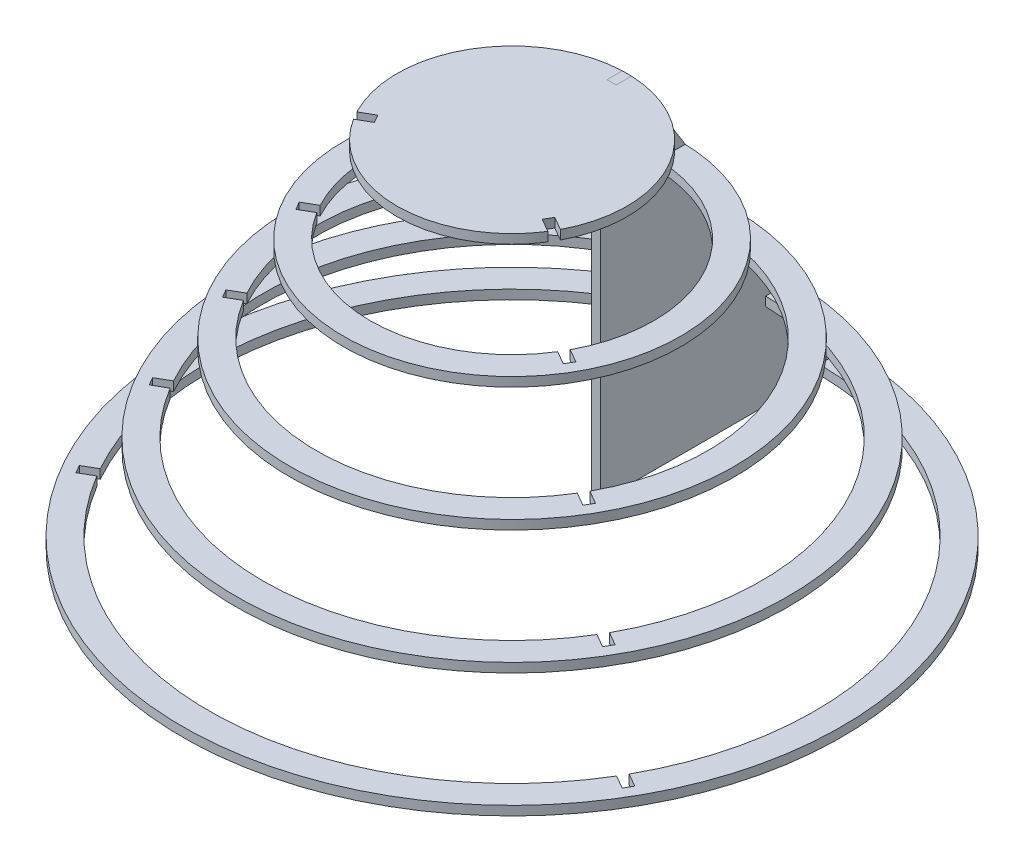
from build123d import *

# Parameters (mm, degrees)
BOSS_EXTRUDE1_DEPTH = 12
SKETCH2_R           = 220
BOSS_EXTRUDE2_DEPTH = 12
SKETCH3_R           = 290
BOSS_EXTRUDE3_DEPTH = 12
SKETCH4_R           = 360
BOSS_EXTRUDE4_DEPTH = 12
SKETCH5_R           = 430
BOSS_EXTRUDE5_DEPTH = 12
BOSS_EXTRUDE6_DEPTH = 12


with BuildPart() as part:
    # Sketch1 → Boss-Extrude1 (new body)
    with BuildSketch(Plane(origin=(0, 0, 0), x_dir=(1, 0, 0), z_dir=(0, 1, 0))):
        with BuildLine():
            Line((109.479337841, -70.136128403), (126.799845917, -80.136128403))
            ThreePointArc((126.799845917, -80.136128403), (0, -150), (-126.799845917, -80.136128403))
            Line((-126.799845917, -80.136128403), (-109.479337841, -70.136128403))
            Line((-109.479337841, -70.136128403), (-115.479337841, -59.743823558))
            Line((-115.479337841, -59.743823558), (-132.799845917, -69.743823558))
            ThreePointArc((-132.799845917, -69.743823558), (-129.903810568, 75), (-6, 149.879951962))
            Line((-6, 149.879951962), (-6, 129.879951962))
            Line((-6, 129.879951962), (6, 129.879951962))
            Line((6, 129.879951962), (6, 149.879951962))
            ThreePointArc((6, 149.879951962), (129.903810568, 75), (132.799845917, -69.743823558))
            Line((132.799845917, -69.743823558), (115.479337841, -59.743823558))
            Line((115.479337841, -59.743823558), (109.479337841, -70.136128403))
        make_face()
    extrude(amount=BOSS_EXTRUDE1_DEPTH)


with BuildPart() as body_2:
    # Sketch2 → Boss-Extrude2 (new body)
    with BuildSketch(Plane(origin=(0, -100, 0), x_dir=(-1, 0, 0), z_dir=(0, -1, 0))):
        Circle(SKETCH2_R)
        with BuildLine():
            Line((180.436842735, -97.247056494), (163.130415599, -87.255186129))
            ThreePointArc((163.130415599, -87.255186129), (160.2146997, 92.5), (6, 184.902677103))
            Line((6, 184.902677103), (6, 204.886417834))
            Line((6, 204.886417834), (-6, 204.886417834))
            Line((-6, 204.886417834), (-6, 184.902677103))
            ThreePointArc((-6, 184.902677103), (-160.2146997, 92.5), (-163.130415599, -87.255186129))
            Line((-163.130415599, -87.255186129), (-180.436842735, -97.247056494))
            Line((-180.436842735, -97.247056494), (-174.436842735, -107.63936134))
            Line((-174.436842735, -107.63936134), (-157.130415599, -97.647490974))
            ThreePointArc((-157.130415599, -97.647490974), (0, -185), (157.130415599, -97.647490974))
            Line((157.130415599, -97.647490974), (174.436842735, -107.63936134))
            Line((174.436842735, -107.63936134), (180.436842735, -97.247056494))
        make_face(mode=Mode.SUBTRACT)
    extrude(amount=BOSS_EXTRUDE2_DEPTH)


with BuildPart() as body_3:
    # Sketch3 → Boss-Extrude3 (new body)
    with BuildSketch(Plane(origin=(0, -212, 0), x_dir=(-1, 0, 0), z_dir=(0, -1, 0))):
        Circle(SKETCH3_R)
        with BuildLine():
            Line((241.095846372, -132.268548573), (223.775338297, -122.268548573))
            ThreePointArc((223.775338297, -122.268548573), (220.836477965, 127.5), (6, 254.929401992))
            Line((6, 254.929401992), (6, 274.929401992))
            Line((6, 274.929401992), (-6, 274.929401992))
            Line((-6, 274.929401992), (-6, 254.929401992))
            ThreePointArc((-6, 254.929401992), (-220.836477965, 127.5), (-223.775338297, -122.268548573))
            Line((-223.775338297, -122.268548573), (-241.095846372, -132.268548573))
            Line((-241.095846372, -132.268548573), (-235.095846372, -142.660853419))
            Line((-235.095846372, -142.660853419), (-217.775338297, -132.660853419))
            ThreePointArc((-217.775338297, -132.660853419), (0, -255), (217.775338297, -132.660853419))
            Line((217.775338297, -132.660853419), (235.095846372, -142.660853419))
            Line((235.095846372, -142.660853419), (241.095846372, -132.268548573))
        make_face(mode=Mode.SUBTRACT)
    extrude(amount=BOSS_EXTRUDE3_DEPTH)


with BuildPart() as body_4:
    # Sketch4 → Boss-Extrude4 (new body)
    with BuildSketch(Plane(origin=(0, -324, 0), x_dir=(-1, 0, 0), z_dir=(0, -1, 0))):
        Circle(SKETCH4_R)
        with BuildLine():
            Line((301.730795734, -167.27615291), (284.410287658, -157.27615291))
            ThreePointArc((284.410287658, -157.27615291), (281.45825623, 162.5), (6, 324.944610665))
            Line((6, 324.944610665), (6, 344.944610665))
            Line((6, 344.944610665), (-6, 344.944610665))
            Line((-6, 344.944610665), (-6, 324.944610665))
            ThreePointArc((-6, 324.944610665), (-281.45825623, 162.5), (-284.410287658, -157.27615291))
            Line((-284.410287658, -157.27615291), (-301.730795734, -167.27615291))
            Line((-301.730795734, -167.27615291), (-295.730795734, -177.668457755))
            Line((-295.730795734, -177.668457755), (-278.410287658, -167.668457755))
            ThreePointArc((-278.410287658, -167.668457755), (0, -325), (278.410287658, -167.668457755))
            Line((278.410287658, -167.668457755), (295.730795734, -177.668457755))
            Line((295.730795734, -177.668457755), (301.730795734, -167.27615291))
        make_face(mode=Mode.SUBTRACT)
    extrude(amount=BOSS_EXTRUDE4_DEPTH)


with BuildPart() as body_5:
    # Sketch5 → Boss-Extrude5 (new body)
    with BuildSketch(Plane(origin=(0, -436, 0), x_dir=(-1, 0, 0), z_dir=(0, -1, 0))):
        Circle(SKETCH5_R)
        with BuildLine():
            Line((362.361075845, -202.281061453), (345.040567769, -192.281061453))
            ThreePointArc((345.040567769, -192.281061453), (342.080034495, 197.5), (6, 394.954427751))
            Line((6, 394.954427751), (6, 414.954427751))
            Line((6, 414.954427751), (-6, 414.954427751))
            Line((-6, 414.954427751), (-6, 394.954427751))
            ThreePointArc((-6, 394.954427751), (-342.080034495, 197.5), (-345.040567769, -192.281061453))
            Line((-345.040567769, -192.281061453), (-362.361075845, -202.281061453))
            Line((-362.361075845, -202.281061453), (-356.361075845, -212.673366298))
            Line((-356.361075845, -212.673366298), (-339.040567769, -202.673366298))
            ThreePointArc((-339.040567769, -202.673366298), (0, -395), (339.040567769, -202.673366298))
            Line((339.040567769, -202.673366298), (356.361075845, -212.673366298))
            Line((356.361075845, -212.673366298), (362.361075845, -202.281061453))
        make_face(mode=Mode.SUBTRACT)
    extrude(amount=BOSS_EXTRUDE5_DEPTH)


with BuildPart() as body_6:
    # Sketch7 → Boss-Extrude6 (new body)
    with BuildSketch(Plane(origin=(-6, 0, 0), x_dir=(0, 0, -1), z_dir=(1, 0, 0))):
        Polygon((109.688052229, -448), (414.954427751, -448), (414.954427751, -436), (430, -436), (360, -336), (344.944610665, -336), (344.944610665, -324), (360, -324), (290, -224), (274.929401992, -224), (274.929401992, -212), (290, -212), (220, -112), (204.886417834, -112), (204.886417834, -100), (220, -100), (149.879951962, 12), (129.879951962, 12), (129.879951962, 0), (109.688052229, 0), align=None)
    extrude(amount=BOSS_EXTRUDE6_DEPTH)


solid = Compound([part.part, body_2.part, body_3.part, body_4.part, body_5.part, body_6.part])
